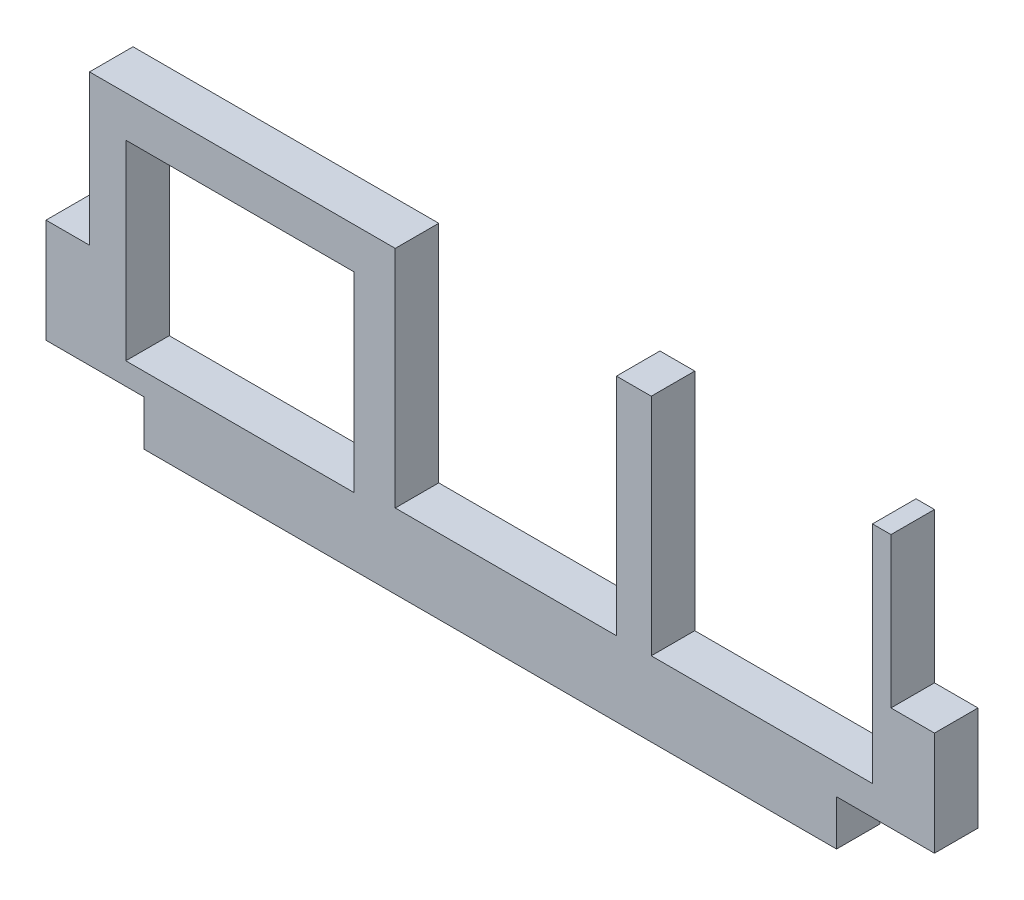
from build123d import *

# Parameters (mm, degrees)
BOSS_EXTRUDE1_DEPTH = 3.048
SKETCH2_W           = 18.542
SKETCH2_H           = 2.8702
BOSS_EXTRUDE2_DEPTH = 3.048


with BuildPart() as part:
    # Sketch1 → Boss-Extrude1 (new body)
    with BuildSketch(Plane.XY):
        Polygon((-3.048, 12.0142), (0, 12.0142), (0, 19.6596), (2.54, 19.6596), (2.54, 6.2738), (18.542, 6.2738), (18.542, 22.5298), (21.4122, 22.5298), (21.4122, 6.7818), (36.9062, 6.7818), (36.9062, 22.5298), (39.3446, 22.5298), (39.3446, 6.7818), (54.8386, 6.7818), (54.8386, 22.5298), (56.134, 22.5298), (56.134, 12.0142), (59.182, 12.0142), (59.182, 4.7244), (52.324, 4.7244), (52.324, 1.5494), (3.81, 1.5494), (3.81, 4.7244), (-3.048, 4.7244), align=None)
    extrude(amount=BOSS_EXTRUDE1_DEPTH)

    # Sketch2 → Boss-Extrude2 (add)
    with BuildSketch(Plane.XY.offset(3.048)):
        with Locations((9.271, 21.0947)):
            Rectangle(SKETCH2_W, SKETCH2_H)
    extrude(amount=-BOSS_EXTRUDE2_DEPTH)


solid = part.part
